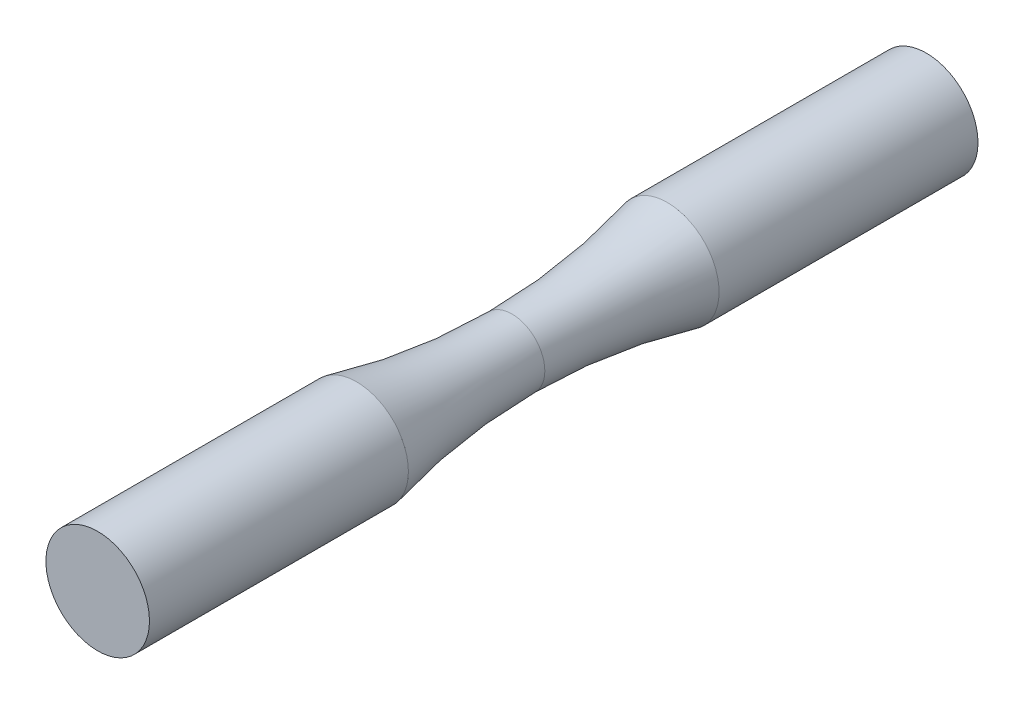
from build123d import *

# Parameters (mm, degrees)
SKETCH2_R           = 6.35
BOSS_EXTRUDE1_DEPTH = 31.75
SKETCH8_R           = 6.35
BOSS_EXTRUDE2_DEPTH = 31.75


with BuildPart() as part:
    # Sketch2 → Boss-Extrude1 (new body)
    with BuildSketch(Plane.XY):
        Circle(SKETCH2_R)
    extrude(amount=BOSS_EXTRUDE1_DEPTH)

    # Sketch7 → Revolve1 (revolve)
    with BuildSketch(Plane(origin=(0, 0, 0), x_dir=(0, 0, -1), z_dir=(1, 0, 0))):
        with BuildLine():
            Line((-31.75, 0), (-31.75, 6.35))
            ThreePointArc((-31.75, 6.35), (-50.8, 4.03225), (-69.85, 6.35))
            Line((-69.85, 6.35), (-69.85, 0))
            Line((-69.85, 0), (-31.75, 0))
        make_face()
    revolve(axis=Axis((0, 0, 0), (0, 0, 1)))

    # Sketch8 → Boss-Extrude2 (add)
    with BuildSketch(Plane.XY.offset(69.85)):
        Circle(SKETCH8_R)
    extrude(amount=BOSS_EXTRUDE2_DEPTH)


solid = part.part
